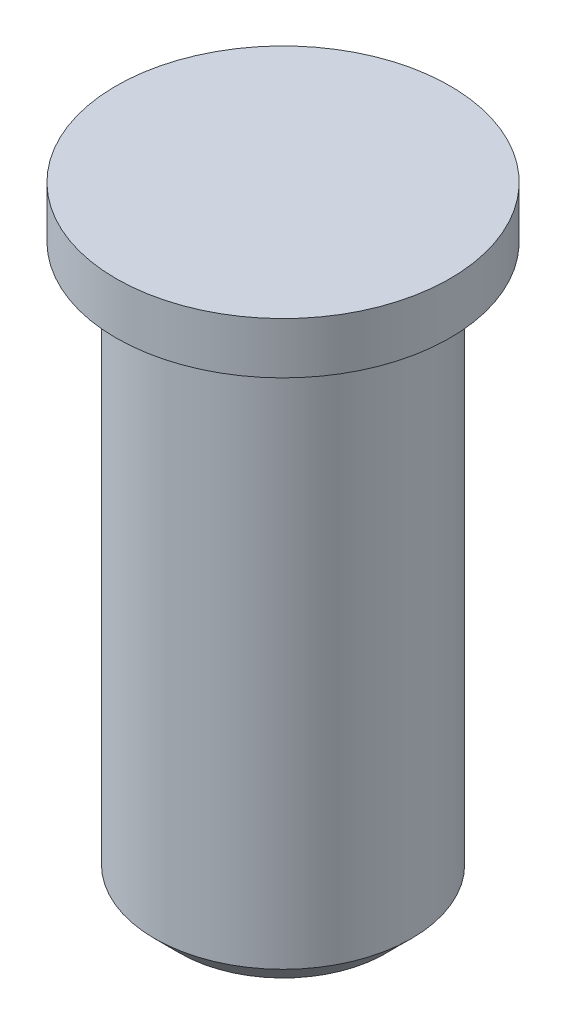
from build123d import *

# Parameters (mm, degrees)
CHAFL_N1_SIZE = 0.5


with BuildPart() as part:
    # Croquis1 → Revolución1 (revolve)
    with BuildSketch(Plane.XY):
        Polygon((0, 0), (3.25, 0), (3.25, -1), (2.5, -1), (2.5, -12), (0, -12), align=None)
    revolve(axis=Axis((0, 0, 0), (0, -1, 0)))

    # Chaflán1
    chafl_n1_edges = [part.edges().sort_by_distance(p)[0] for p in [
        (-2.5, -12, 0),
    ]]
    chamfer(chafl_n1_edges, length=CHAFL_N1_SIZE)


solid = part.part
